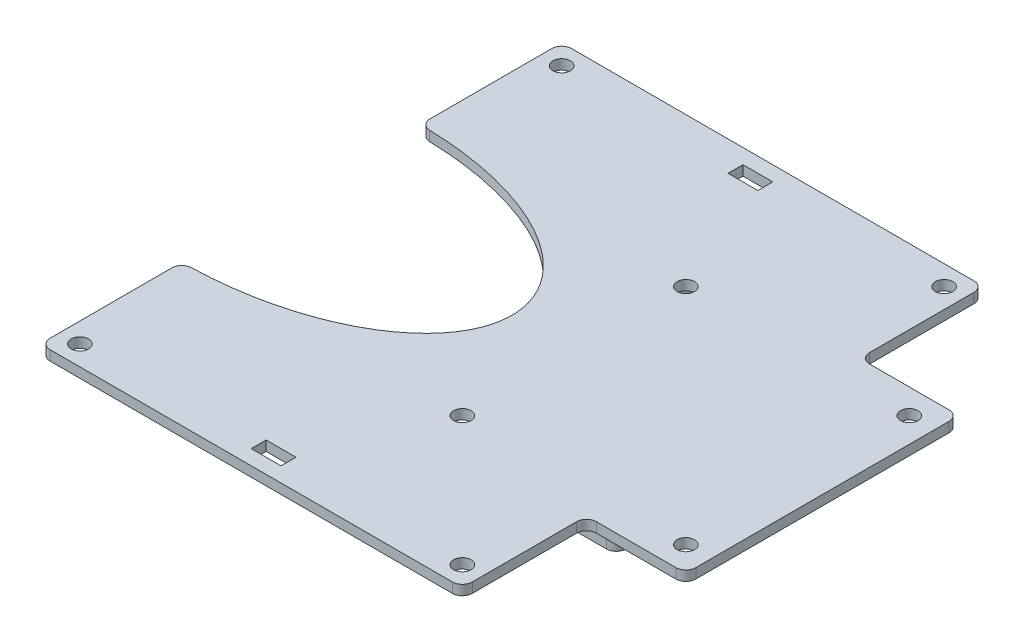
from build123d import *

# Parameters (mm, degrees)
SKETCH1_R           = 1.75
SKETCH1_W           = 6
SKETCH1_H           = 3
BOSS_EXTRUDE1_DEPTH = 2
BOSS_EXTRUDE2_DEPTH = 6
SKETCH4_RX          = 42.5
SKETCH4_RY          = 24
CUT_EXTRUDE1_DEPTH  = 2
BOSS_EXTRUDE3_DEPTH = 17
FILLET1_R           = 2
CUT_EXTRUDE2_START  = -6
SKETCH2_3_W         = 12
SKETCH2_3_H         = 7
CUT_EXTRUDE2_DEPTH  = 2
CUT_EXTRUDE3_START  = -17
SKETCH3_3_W         = 7
SKETCH3_3_H         = 12
CUT_EXTRUDE3_DEPTH  = 2


with BuildPart() as part:
    # Sketch1 → Boss-Extrude1 (new body)
    with BuildSketch(Plane(origin=(0, 0, 0), x_dir=(1, 0, 0), z_dir=(0, 1, 0))):
        Polygon((-100.077357964, 56.197183099), (-15.077357964, 56.197183099), (-15.077357964, 31.197183099), (4.922642036, 31.197183099), (4.922642036, -23.802816901), (-15.077357964, -23.802816901), (-15.077357964, -48.802816901), (-100.077357964, -48.802816901), align=None)
        with Locations(Location((-96.077357964, 52.197183099, 0), (0, 0, 270))):  # turned: the seam where the file's is
            Circle(SKETCH1_R, mode=Mode.SUBTRACT)
        with Locations(Location((-96.077357964, -44.802816901, 0), (0, 0, 270))):  # turned: the seam where the file's is
            Circle(SKETCH1_R, mode=Mode.SUBTRACT)
        with Locations(Location((-19.077357964, -44.802816901, 0), (0, 0, 270))):  # turned: the seam where the file's is
            Circle(SKETCH1_R, mode=Mode.SUBTRACT)
        with Locations(Location((-19.077357964, 52.197183099, 0), (0, 0, 270))):  # turned: the seam where the file's is
            Circle(SKETCH1_R, mode=Mode.SUBTRACT)
        with Locations(Location((-0.077357964, 26.197183099, 0), (0, 0, 270))):  # turned: the seam where the file's is
            Circle(SKETCH1_R, mode=Mode.SUBTRACT)
        with Locations(Location((-0.077357964, -18.802816901, 0), (0, 0, 270))):  # turned: the seam where the file's is
            Circle(SKETCH1_R, mode=Mode.SUBTRACT)
        with Locations(Location((-45.077357964, 26.197183099, 0), (0, 0, 270))):  # turned: the seam where the file's is
            Circle(SKETCH1_R, mode=Mode.SUBTRACT)
        with Locations(Location((-45.077357964, -18.802816901, 0), (0, 0, 270))):  # turned: the seam where the file's is
            Circle(SKETCH1_R, mode=Mode.SUBTRACT)
        with Locations((-57.581758556, 51.697183099)):
            Rectangle(SKETCH1_W, SKETCH1_H, mode=Mode.SUBTRACT)
        with Locations((-57.577357964, -44.302816901)):
            Rectangle(SKETCH1_W, SKETCH1_H, mode=Mode.SUBTRACT)
    extrude(amount=BOSS_EXTRUDE1_DEPTH)

    # Sketch2 → Boss-Extrude2 (add)
    with BuildSketch(Plane(origin=(0, 0, 0), x_dir=(1, 0, 0), z_dir=(0, 1, 0))):
        with BuildLine():
            Line((-48.827357964, 32.697183099), (-48.827357964, 31.525610223))
            ThreePointArc((-48.827357964, 31.525610223), (-49.010861383, 30.948259954), (-49.494024631, 30.582801182))
            ThreePointArc((-49.494024631, 30.582801182), (-50.827357964, 28.697183099), (-49.494024631, 26.811565015))
            ThreePointArc((-49.494024631, 26.811565015), (-49.010861383, 26.446106243), (-48.827357964, 25.868755974))
            Line((-48.827357964, 25.868755974), (-48.827357964, 24.697183099))
            ThreePointArc((-48.827357964, 24.697183099), (-49.413144402, 23.282969536), (-50.827357964, 22.697183099))
            Line((-50.827357964, 22.697183099), (-64.327357964, 22.697183099))
            ThreePointArc((-64.327357964, 22.697183099), (-65.741571527, 23.282969536), (-66.327357964, 24.697183099))
            Line((-66.327357964, 24.697183099), (-66.327357964, 32.697183099))
            ThreePointArc((-66.327357964, 32.697183099), (-65.741571527, 34.111396661), (-64.327357964, 34.697183099))
            Line((-64.327357964, 34.697183099), (-50.827357964, 34.697183099))
            ThreePointArc((-50.827357964, 34.697183099), (-49.413144402, 34.111396661), (-48.827357964, 32.697183099))
        make_face()
        with BuildLine():
            Line((-48.822971012, -17.300189586), (-48.822971012, -18.471355074))
            ThreePointArc((-48.822971012, -18.471355074), (-49.00663465, -19.04893186), (-49.4901609, -19.414348939))
            ThreePointArc((-49.4901609, -19.414348939), (-50.8246687, -21.299453668), (-49.492167868, -23.185977571))
            ThreePointArc((-49.492167868, -23.185977571), (-49.009337779, -23.551474397), (-48.825981367, -24.128616711))
            Line((-48.825981367, -24.128616711), (-48.825981367, -25.300189586))
            ThreePointArc((-48.825981367, -25.300189586), (-49.411767805, -26.714403149), (-50.825981367, -27.300189586))
            Line((-50.825981367, -27.300189586), (-64.322971012, -27.300189586))
            ThreePointArc((-64.322971012, -27.300189586), (-65.737184574, -26.714403149), (-66.322971012, -25.300189586))
            Line((-66.322971012, -25.300189586), (-66.322971012, -17.300189586))
            ThreePointArc((-66.322971012, -17.300189586), (-65.737184574, -15.885976024), (-64.322971012, -15.300189586))
            Line((-64.322971012, -15.300189586), (-50.822971012, -15.300189586))
            ThreePointArc((-50.822971012, -15.300189586), (-49.408757449, -15.885976024), (-48.822971012, -17.300189586))
        make_face()
    extrude(amount=-BOSS_EXTRUDE2_DEPTH)

    # Sketch4 → Cut-Extrude1 (cut)
    with BuildSketch(Plane(origin=(0, 0, 0), x_dir=(1, 0, 0), z_dir=(0, 1, 0))):
        with Locations(Location((-100.077357964, 3.697183099), (0, 0, 0))):
            Ellipse(SKETCH4_RX, SKETCH4_RY)
    extrude(amount=CUT_EXTRUDE1_DEPTH, mode=Mode.SUBTRACT)

    # Sketch3 → Boss-Extrude3 (add)
    with BuildSketch(Plane(origin=(0, 0, 0), x_dir=(1, 0, 0), z_dir=(0, 1, 0))):
        with BuildLine():
            Line((-32.827357964, 15.947183099), (-26.327357964, 15.947183099))
            ThreePointArc((-26.327357964, 15.947183099), (-24.913144402, 15.361396661), (-24.327357964, 13.947183099))
            Line((-24.327357964, 13.947183099), (-24.327357964, -6.552816901))
            ThreePointArc((-24.327357964, -6.552816901), (-24.913144402, -7.967030464), (-26.327357964, -8.552816901))
            Line((-26.327357964, -8.552816901), (-32.827357964, -8.552816901))
            ThreePointArc((-32.827357964, -8.552816901), (-34.241571527, -7.967030464), (-34.827357964, -6.552816901))
            Line((-34.827357964, -6.552816901), (-34.827357964, 13.947183099))
            ThreePointArc((-34.827357964, 13.947183099), (-34.241571527, 15.361396661), (-32.827357964, 15.947183099))
        make_face()
    extrude(amount=-BOSS_EXTRUDE3_DEPTH)

    # Fillet1
    fillet1_edges = [part.edges().sort_by_distance(p)[0] for p in [
        (-100.077357964, 1, -56.197183099),
        (-100.077357964, 1, -27.697183099),
        (-100.077357964, 1, 20.302816901),
        (-100.077357964, 1, 48.802816901),
        (-15.077357964, 1, 48.802816901),
        (-15.077357964, 1, 23.802816901),
        (4.922642036, 1, 23.802816901),
        (4.922642036, 1, -31.197183099),
        (-15.077357964, 1, -31.197183099),
        (-15.077357964, 1, -56.197183099),
    ]]
    fillet(fillet1_edges, radius=FILLET1_R)

    # Sketch2_3 → Cut-Extrude2 (cut)
    with BuildSketch(Plane(origin=(0, 0, 0), x_dir=(1, 0, 0), z_dir=(0, 1, 0)).offset(CUT_EXTRUDE2_START)):
        with Locations((-57.577357964, 28.697183099)):
            Rectangle(SKETCH2_3_W, SKETCH2_3_H)
        with Locations((-57.574476189, -21.300189586)):
            Rectangle(SKETCH2_3_W, SKETCH2_3_H)
    extrude(amount=CUT_EXTRUDE2_DEPTH, mode=Mode.SUBTRACT)

    # Sketch3_3 → Cut-Extrude3 (cut)
    with BuildSketch(Plane(origin=(0, 0, 0), x_dir=(1, 0, 0), z_dir=(0, 1, 0)).offset(CUT_EXTRUDE3_START)):
        with Locations((-29.577357964, 3.697183099)):
            Rectangle(SKETCH3_3_W, SKETCH3_3_H)
    extrude(amount=CUT_EXTRUDE3_DEPTH, mode=Mode.SUBTRACT)


solid = part.part
